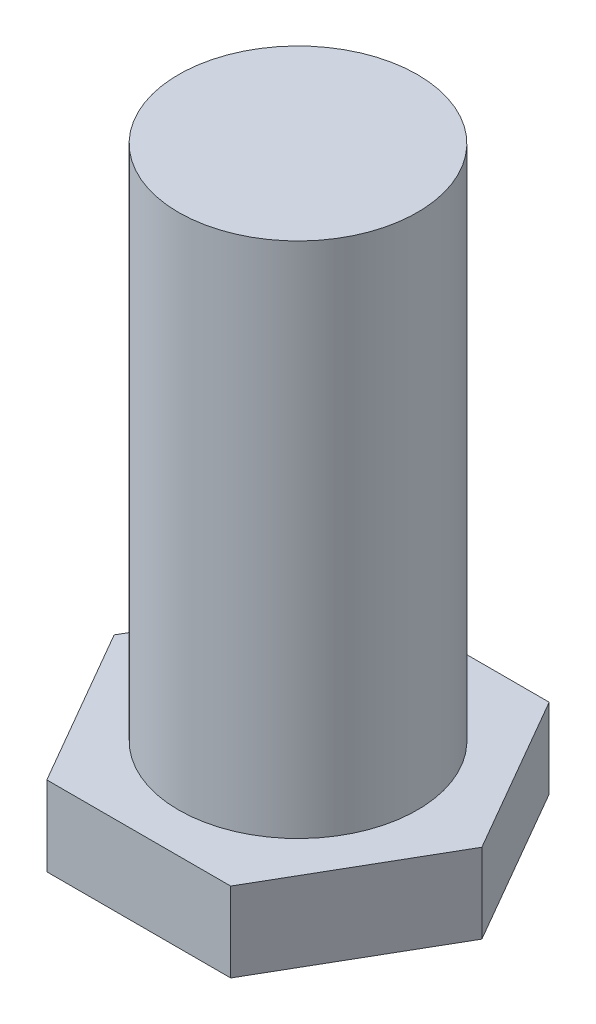
from build123d import *

# Parameters (mm, degrees)
EXTRUDE_1_DEPTH = 2
SKETCH_2_R      = 3
EXTRUDE_2_DEPTH = 15


with BuildPart() as part:
    # 草圖1 → 填料-伸長1 (new body)
    with BuildSketch(Plane(origin=(0, 0, 0), x_dir=(1, 0, 0), z_dir=(0, 1, 0))):
        Polygon((4.618802154, 0), (2.309401077, 4), (-2.309401077, 4), (-4.618802154, 0), (-2.309401077, -4), (2.309401077, -4), align=None)
    extrude(amount=EXTRUDE_1_DEPTH)

    # 草圖2 → 填料-伸長2 (add)
    with BuildSketch(Plane(origin=(0, 0, 0), x_dir=(1, 0, 0), z_dir=(0, 1, 0))):
        Circle(SKETCH_2_R)
    extrude(amount=EXTRUDE_2_DEPTH)


solid = part.part
